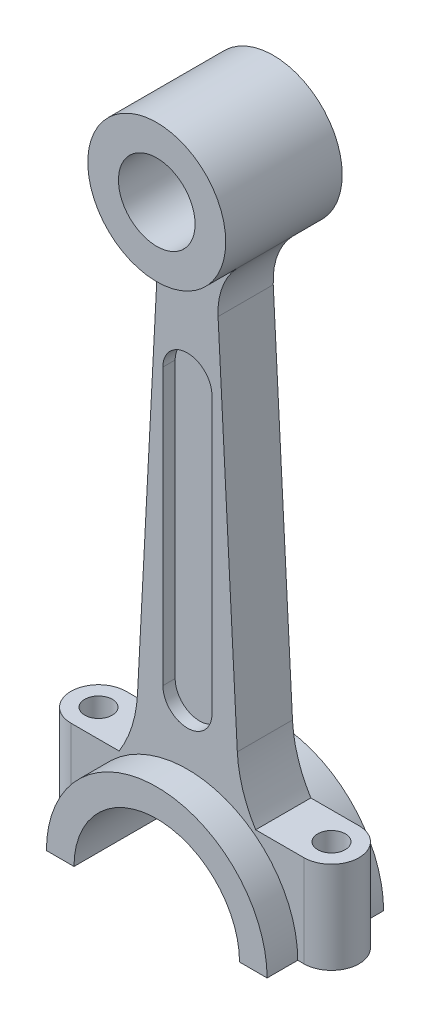
from build123d import *

# Parameters (mm, degrees)
SKETCH1_R             = 22.5
BOSS_EXTRUDE1_DEPTH   = 19
BOSS_EXTRUDE1_2_DEPTH = 19
BOSS_EXTRUDE2_DEPTH   = 9
CUT_EXTRUDE1_DEPTH    = 4
SKETCH6_W             = 94
SKETCH6_H             = 30
BOSS_EXTRUDE3_DEPTH   = 9
SKETCH4_R             = 12.5
CUT_EXTRUDE2_DEPTH    = 39
SKETCH5_R             = 4.5
CUT_EXTRUDE3_DEPTH    = 224.7
CUT_EXTRUDE4_DEPTH    = 224.7


with BuildPart() as part:
    # Sketch1 → Boss-Extrude1 (new body, symmetric)
    with BuildSketch(Plane.XY):
        Circle(SKETCH1_R)
    extrude(amount=BOSS_EXTRUDE1_DEPTH, both=True)



with BuildPart() as body_2:
    # Sketch1 → Boss-Extrude1 2 (new body, symmetric)
    with BuildSketch(Plane.XY):
        with BuildLine():
            Line((-36, -201.2), (36, -201.2))
            ThreePointArc((36, -201.2), (0, -165.2), (-36, -201.2))
        make_face()
    extrude(amount=BOSS_EXTRUDE1_2_DEPTH, both=True)


with BuildPart() as part_1:
    add(part.part)

    add(body_2.part)  # Boss-Extrude2 merges body 2
    # Sketch2 → Boss-Extrude2 (add, symmetric)
    with BuildSketch(Plane.XY):
        with BuildLine():
            Line((-16.279722223, -152.158712146), (-10, -32.334474052))
            ThreePointArc((-10, -32.334474052), (-11.381584619, -23.310643729), (-16.234582266, -15.578457518))
            ThreePointArc((-16.234582266, -15.578457518), (0, -22.5), (16.234582266, -15.578457518))
            ThreePointArc((16.234582266, -15.578457518), (11.381584619, -23.310643729), (10, -32.334474052))
            Line((10, -32.334474052), (16.279722223, -152.158712146))
            ThreePointArc((16.279722223, -152.158712146), (19.307974883, -165.464636648), (26.63284908, -176.978287635))
            ThreePointArc((26.63284908, -176.978287635), (0, -165.2), (-26.63284908, -176.978287635))
            ThreePointArc((-26.63284908, -176.978287635), (-19.307974883, -165.464636648), (-16.279722223, -152.158712146))
        make_face()
    extrude(amount=BOSS_EXTRUDE2_DEPTH, both=True)

    # Sketch3 → Cut-Extrude1 (cut)
    with BuildSketch(Plane.XY.offset(9)):
        with BuildLine():
            Line((-8, -145.6), (-8, -55.6))
            ThreePointArc((-8, -55.6), (0, -47.6), (8, -55.6))
            Line((8, -55.6), (8, -145.6))
            ThreePointArc((8, -145.6), (0, -153.6), (-8, -145.6))
        make_face()
    cut_extrude1 = extrude(amount=-CUT_EXTRUDE1_DEPTH, mode=Mode.SUBTRACT)

    # Mirror1: Cut-Extrude1 across plane
    add(cut_extrude1.mirror(Plane.XY), mode=Mode.SUBTRACT)

    # Sketch6 → Boss-Extrude3 (add, symmetric)
    with BuildSketch(Plane.XY):
        with Locations((0, -186.2)):
            Rectangle(SKETCH6_W, SKETCH6_H)
    extrude(amount=BOSS_EXTRUDE3_DEPTH, both=True)

    # Sketch4 → Cut-Extrude2 (cut, through all)
    with BuildSketch(Plane.XY.offset(19)):
        Circle(SKETCH4_R)
        with BuildLine():
            Line((-27, -201.2), (27, -201.2))
            ThreePointArc((27, -201.2), (0, -174.2), (-27, -201.2))
        make_face()
    extrude(amount=-CUT_EXTRUDE2_DEPTH, mode=Mode.SUBTRACT)

    # Sketch5 → Cut-Extrude3 (cut, through all)
    with BuildSketch(Plane.XZ.offset(201.2)):
        with Locations((-38, 0)):
            Circle(SKETCH5_R)
        with Locations((38, 0)):
            Circle(SKETCH5_R)
    extrude(amount=-CUT_EXTRUDE3_DEPTH, mode=Mode.SUBTRACT)

    # Sketch7 → Cut-Extrude4 (cut, through all)
    with BuildSketch(Plane.XZ.offset(201.2)):
        with BuildLine():
            ThreePointArc((-38, -9), (-44.363961031, -6.363961031), (-47, 0))
            Line((-47, 0), (-47, -9))
            Line((-47, -9), (-38, -9))
        make_face()
        with BuildLine():
            Line((-38, 9), (-47, 9))
            Line((-47, 9), (-47, 0))
            ThreePointArc((-47, 0), (-44.363961031, 6.363961031), (-38, 9))
        make_face()
    cut_extrude4 = extrude(amount=-CUT_EXTRUDE4_DEPTH, mode=Mode.SUBTRACT)

    # Mirror2: Cut-Extrude4 across plane
    add(cut_extrude4.mirror(Plane(origin=(0, 0, 0), x_dir=(0, 0, 1), z_dir=(1, 0, 0))), mode=Mode.SUBTRACT)


solid = part_1.part
